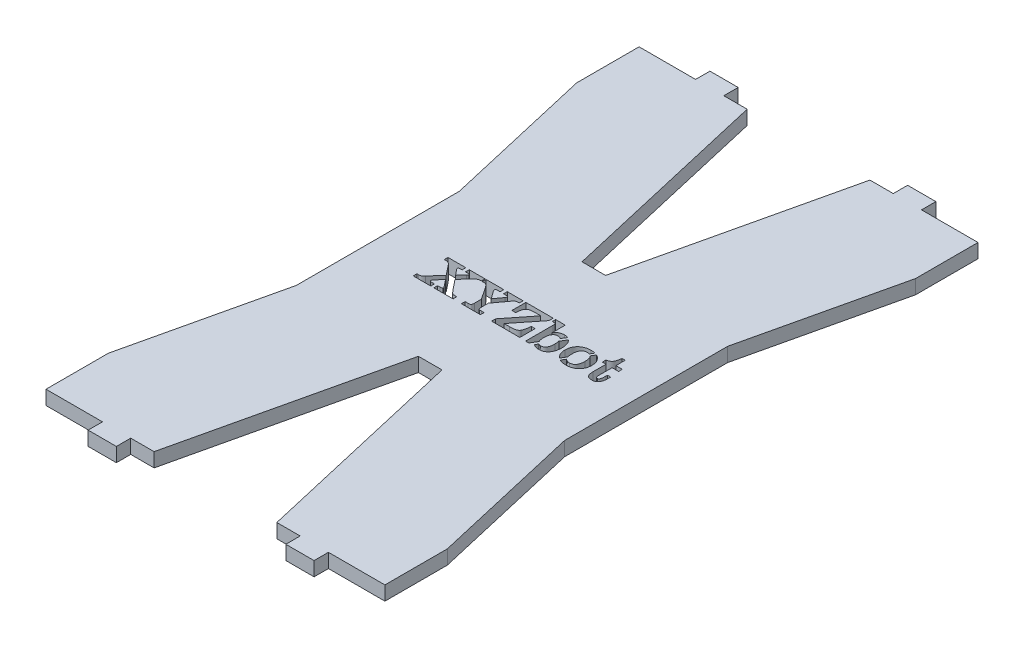
from build123d import *

# Parameters (mm, degrees)
SKETCH1_W            = 76.2
SKETCH1_H            = 133.35
BOSS_EXTRUDE1_DEPTH  = 3.175
SKETCH2_W            = 6.35
SKETCH2_H            = 3.2258
BOSS_EXTRUDE2_DEPTH  = 3.175
CUT_EXTRUDE1_DEPTH   = 4.175
BOSS_EXTRUDE4_DEPTH  = 3.175
CUT_EXTRUDE2_DEPTH   = 4.1750001
MIRROR5_COPY_1_DEPTH = 4.1750001


with BuildPart() as part:
    # Sketch1 → Boss-Extrude1 (new body)
    with BuildSketch(Plane(origin=(0, 0, 0), x_dir=(1, 0, 0), z_dir=(0, 1, 0))):
        Rectangle(SKETCH1_W, SKETCH1_H)
    extrude(amount=BOSS_EXTRUDE1_DEPTH)

    # Sketch2 → Boss-Extrude2 (add)
    with BuildSketch(Plane(origin=(0, 3.175, 0), x_dir=(1, 0, 0), z_dir=(0, 1, 0))):
        with Locations((-22.225, 68.2879)):
            Rectangle(SKETCH2_W, SKETCH2_H)
        with Locations((22.225, 68.2879)):
            Rectangle(SKETCH2_W, SKETCH2_H)
    boss_extrude2 = extrude(amount=-BOSS_EXTRUDE2_DEPTH)

    # Mirror3: Boss-Extrude2 across plane
    add(boss_extrude2.mirror(Plane.XY))

    # Sketch4 → Cut-Extrude1 (cut, through all)
    with BuildSketch(Plane(origin=(0, 3.175, 0), x_dir=(1, 0, 0), z_dir=(0, 1, 0))):
        with BuildLine():
            add(Edge.make_bspline(
                [(-15.638698165, -1.631683837), (-15.690485766, -1.691451515), (-15.78558723, -1.801207394), (-15.883175177, -1.944370795), (-15.939490037, -2.047639577), (-15.966714816, -2.113301537), (-15.987755756, -2.170565282), (-15.989626528, -2.207535866), (-15.990485478, -2.224510605)],
                knots=[0, 0, 0, 0, 0.000237095, 0.000435396, 0.000518457, 0.000589242, 0.000648993, 0.000699717, 0.000699717, 0.000699717, 0.000699717], degree=3))
            add(Edge.make_bspline(
                [(-15.990485478, -2.224510605), (-15.989620457, -2.24753442), (-15.987989932, -2.290933284), (-15.965429023, -2.350427685), (-15.930603393, -2.399456071), (-15.878870991, -2.438412475), (-15.806278072, -2.462600148), (-15.712369072, -2.481831014), (-15.592755408, -2.492103174), (-15.504617179, -2.492835488), (-15.456289929, -2.493237025)],
                knots=[0, 0, 0, 0, 6.8713e-05, 0.00012952, 0.000187834, 0.000247117, 0.000320316, 0.000415184, 0.00053462, 0.000679606, 0.000679606, 0.000679606, 0.000679606], degree=3))
            Line((-15.456289929, -2.493237025), (-14.926980315, -2.493237025))
            Line((-14.926980315, -2.493237025), (-14.926980315, -3.327103248))
            Line((-14.926980315, -3.327103248), (-18.886216229, -3.327103248))
            Line((-18.886216229, -3.327103248), (-18.886216229, -2.493237025))
            Line((-18.886216229, -2.493237025), (-18.490455502, -2.493237025))
            add(Edge.make_bspline(
                [(-18.490455502, -2.493237025), (-18.437747741, -2.491980177), (-18.337968684, -2.489600887), (-18.195873537, -2.47211743), (-18.070682723, -2.441620419), (-17.955028738, -2.397957188), (-17.843575321, -2.326543355), (-17.724242087, -2.228024589), (-17.59237661, -2.097927939), (-17.503945571, -1.998170293), (-17.456265948, -1.944383671)],
                knots=[0, 0, 0, 0, 0.000158113, 0.000299317, 0.000428484, 0.000544015, 0.000668316, 0.000823474, 0.001007748, 0.001223352, 0.001223352, 0.001223352, 0.001223352], degree=3))
            Line((-17.456265948, -1.944383671), (-15.290168142, 0.505098359))
            Line((-15.290168142, 0.505098359), (-17.070277091, 2.734713319))
            add(Edge.make_bspline(
                [(-17.070277091, 2.734713319), (-17.116065653, 2.790336686), (-17.202370607, 2.895178856), (-17.337790854, 3.031316846), (-17.467722941, 3.138633239), (-17.595840588, 3.218984537), (-17.727953317, 3.275645866), (-17.869314565, 3.317284326), (-18.024543569, 3.338860857), (-18.132096521, 3.342137704), (-18.187527538, 3.343826536)],
                knots=[0, 0, 0, 0, 0.000216046, 0.000407216, 0.000575093, 0.000720626, 0.000859205, 0.001005066, 0.001161459, 0.00132778, 0.00132778, 0.00132778, 0.00132778], degree=3))
            Line((-18.187527538, 3.343826536), (-18.573516395, 3.343826536))
            Line((-18.573516395, 3.343826536), (-18.573516395, 4.177692759))
            Line((-18.573516395, 4.177692759), (-14.568678422, 4.177692759))
            Line((-14.568678422, 4.177692759), (-14.568678422, 3.343826536))
            Line((-14.568678422, 3.343826536), (-15.086587521, 3.343826536))
            add(Edge.make_bspline(
                [(-15.086587521, 3.343826536), (-15.11163572, 3.343495713), (-15.158775097, 3.34287312), (-15.224729119, 3.330569344), (-15.282411733, 3.314457662), (-15.328519382, 3.287237596), (-15.366897499, 3.256034669), (-15.392470515, 3.215890579), (-15.410604754, 3.169952911), (-15.411725403, 3.13664339), (-15.412316515, 3.119073531)],
                knots=[0, 0, 0, 0, 7.4988e-05, 0.000141124, 0.000200876, 0.000253398, 0.000300741, 0.000347718, 0.000394611, 0.000446956, 0.000446956, 0.000446956, 0.000446956], degree=3))
            add(Edge.make_bspline(
                [(-15.412316515, 3.119073531), (-15.410329264, 3.093297243), (-15.406137786, 3.038930304), (-15.3713831, 2.955278537), (-15.309502336, 2.865205906), (-15.258685589, 2.802689179), (-15.229908278, 2.767286218)],
                knots=[0, 0, 0, 0, 7.7168e-05, 0.000162761, 0.000267565, 0.00040441, 0.00040441, 0.00040441, 0.00040441], degree=3))
            Line((-15.229908278, 2.767286218), (-14.239692139, 1.565346233))
            Line((-14.239692139, 1.565346233), (-13.032866218, 2.822660147))
            add(Edge.make_bspline(
                [(-13.032866218, 2.822660147), (-13.007017433, 2.850210094), (-12.957830972, 2.90263362), (-12.901636695, 2.987359082), (-12.861415365, 3.065389667), (-12.853760882, 3.117681889), (-12.850457982, 3.140245916)],
                knots=[0, 0, 0, 0, 0.000113071, 0.000215157, 0.000304792, 0.000372825, 0.000372825, 0.000372825, 0.000372825], degree=3))
            add(Edge.make_bspline(
                [(-12.850457982, 3.140245916), (-12.852055675, 3.156282141), (-12.855208996, 3.187932388), (-12.880309202, 3.231662924), (-12.922132284, 3.265634911), (-12.977179601, 3.295409505), (-13.048048121, 3.316977615), (-13.13376831, 3.332929053), (-13.235160774, 3.342282138), (-13.308087636, 3.343287442), (-13.347194697, 3.343826536)],
                knots=[0, 0, 0, 0, 4.7928e-05, 9.4593e-05, 0.000146531, 0.000207752, 0.000281402, 0.000367643, 0.000469091, 0.000586399, 0.000586399, 0.000586399, 0.000586399], degree=3))
            Line((-13.347194697, 3.343826536), (-13.786928838, 3.343826536))
            Line((-13.786928838, 3.343826536), (-13.786928838, 4.177692759))
            Line((-13.786928838, 4.177692759), (-10.234854165, 4.177692759))
            Line((-10.234854165, 4.177692759), (-10.234854165, 3.343826536))
            Line((-10.234854165, 3.343826536), (-10.642015407, 3.343826536))
            add(Edge.make_bspline(
                [(-10.642015407, 3.343826536), (-10.680299077, 3.34101395), (-10.761889231, 3.335019767), (-10.886186414, 3.292096874), (-11.019653992, 3.227079161), (-11.163324398, 3.136506756), (-11.315287356, 3.0179238), (-11.477991165, 2.875617342), (-11.651720779, 2.709046671), (-11.765933978, 2.58500885), (-11.826040298, 2.519732183)],
                knots=[0, 0, 0, 0, 0.000114747, 0.000244549, 0.000390964, 0.000559975, 0.000752817, 0.00096869, 0.001208273, 0.001474421, 0.001474421, 0.001474421, 0.001474421], degree=3))
            Line((-11.826040298, 2.519732183), (-11.837440813, 2.508331668))
            Line((-11.837440813, 2.508331668), (-13.506801904, 0.685877951))
            Line((-13.506801904, 0.685877951), (-11.589886778, -1.696829636))
            add(Edge.make_bspline(
                [(-11.589886778, -1.696829636), (-11.553793764, -1.741580619), (-11.484833981, -1.82708243), (-11.381555416, -1.945997428), (-11.286387937, -2.052273964), (-11.196219336, -2.142998616), (-11.114982366, -2.222686528), (-11.039077004, -2.287057271), (-10.970786068, -2.338993086), (-10.885133086, -2.388731663), (-10.768411532, -2.430971532), (-10.612923251, -2.468822484), (-10.431847279, -2.488295337), (-10.303292571, -2.491520207), (-10.234854165, -2.493237025)],
                knots=[0, 0, 0, 0, 0.00017246, 0.000329504, 0.000472472, 0.000600308, 0.000713191, 0.000813706, 0.000898724, 0.000970236, 0.001109968, 0.001269159, 0.001449556, 0.001654927, 0.001654927, 0.001654927, 0.001654927], degree=3))
            Line((-10.234854165, -2.493237025), (-9.922154332, -2.493237025))
            Line((-9.922154332, -2.493237025), (-9.922154332, -3.327103248))
            Line((-9.922154332, -3.327103248), (-14.239692139, -3.327103248))
            Line((-14.239692139, -3.327103248), (-14.239692139, -2.493237025))
            Line((-14.239692139, -2.493237025), (-13.721783039, -2.493237025))
            add(Edge.make_bspline(
                [(-13.721783039, -2.493237025), (-13.678892894, -2.492517178), (-13.599538096, -2.491185328), (-13.48943544, -2.484121276), (-13.398086192, -2.469200598), (-13.32303738, -2.45168885), (-13.265098193, -2.423318795), (-13.222260179, -2.387916962), (-13.196700104, -2.341137923), (-13.193925025, -2.307337082), (-13.192473425, -2.289656404)],
                knots=[0, 0, 0, 0, 0.000128704, 0.000238127, 0.000330501, 0.000406351, 0.000468261, 0.000522498, 0.000570591, 0.00062334, 0.00062334, 0.00062334, 0.00062334], degree=3))
            add(Edge.make_bspline(
                [(-13.192473425, -2.289656404), (-13.194174591, -2.261801444), (-13.197736273, -2.203482329), (-13.224131195, -2.115776548), (-13.26309585, -2.025701673), (-13.303651651, -1.971900138), (-13.324393667, -1.944383671)],
                knots=[0, 0, 0, 0, 8.3459e-05, 0.000174736, 0.000273131, 0.000376135, 0.000376135, 0.000376135, 0.000376135], degree=3))
            Line((-13.324393667, -1.944383671), (-14.558906552, -0.390656372))
            Line((-14.558906552, -0.390656372), (-15.638698165, -1.631683837))
        make_face()
        with BuildLine():
            add(Edge.make_bspline(
                [(-5.127423549, -1.796176979), (-5.125840843, -1.86514528), (-5.122990046, -1.989372053), (-5.104314954, -2.15639366), (-5.069354339, -2.282370853), (-5.023912537, -2.363797322), (-4.971161517, -2.403080683), (-4.923115364, -2.427054709), (-4.864193973, -2.448453956), (-4.793275858, -2.463068058), (-4.712197141, -2.479425369), (-4.618752394, -2.485068094), (-4.514643876, -2.493170108), (-4.441245033, -2.493213975), (-4.402676539, -2.493237025)],
                knots=[0, 0, 0, 0, 0.000206998, 0.000372848, 0.000502169, 0.000598851, 0.000644132, 0.000697307, 0.000759644, 0.000831544, 0.000914285, 0.001007474, 0.001111911, 0.001227556, 0.001227556, 0.001227556, 0.001227556], degree=3))
            Line((-4.402676539, -2.493237025), (-3.772390937, -2.493237025))
            Line((-3.772390937, -2.493237025), (-3.772390937, -3.327103248))
            Line((-3.772390937, -3.327103248), (-8.04595533, -3.327103248))
            Line((-8.04595533, -3.327103248), (-8.04595533, -2.493237025))
            Line((-8.04595533, -2.493237025), (-7.410783793, -2.493237025))
            add(Edge.make_bspline(
                [(-7.410783793, -2.493237025), (-7.372219211, -2.493191042), (-7.298827813, -2.493103533), (-7.19466939, -2.485294067), (-7.101475721, -2.478718268), (-7.020507916, -2.46540101), (-6.950392646, -2.449783487), (-6.892787526, -2.428719804), (-6.84484373, -2.406110137), (-6.792918514, -2.366917988), (-6.746923129, -2.285954663), (-6.715060941, -2.15861047), (-6.692460689, -1.99126836), (-6.691471219, -1.865754228), (-6.690922718, -1.796176979)],
                knots=[0, 0, 0, 0, 0.000115645, 0.000220082, 0.000313271, 0.000395739, 0.000466054, 0.000528391, 0.000579376, 0.000624657, 0.000721339, 0.000850197, 0.001017877, 0.001226445, 0.001226445, 0.001226445, 0.001226445], degree=3))
            Line((-6.690922718, -1.796176979), (-6.690922718, -0.193590331))
            Line((-6.690922718, -0.193590331), (-8.529662885, 2.563705597))
            add(Edge.make_bspline(
                [(-8.529662885, 2.563705597), (-8.578130173, 2.632264546), (-8.669101195, 2.760946752), (-8.810745181, 2.931305021), (-8.945353419, 3.067760726), (-9.075794777, 3.173600039), (-9.207864949, 3.250371117), (-9.345175809, 3.30592008), (-9.491930187, 3.336643223), (-9.592491862, 3.341404218), (-9.643656042, 3.343826536)],
                knots=[0, 0, 0, 0, 0.000251814, 0.000472644, 0.000663814, 0.000826091, 0.000974976, 0.001120446, 0.001268662, 0.001422179, 0.001422179, 0.001422179, 0.001422179], degree=3))
            Line((-9.643656042, 3.343826536), (-10.026387609, 3.343826536))
            Line((-10.026387609, 3.343826536), (-10.026387609, 4.177692759))
            Line((-10.026387609, 4.177692759), (-6.036207441, 4.177692759))
            Line((-6.036207441, 4.177692759), (-6.036207441, 3.343826536))
            Line((-6.036207441, 3.343826536), (-6.57691757, 3.343826536))
            add(Edge.make_bspline(
                [(-6.57691757, 3.343826536), (-6.616049839, 3.343477281), (-6.689080356, 3.342825483), (-6.789806409, 3.331238358), (-6.874625283, 3.314694557), (-6.942165524, 3.288634697), (-6.996061598, 3.25669823), (-7.030858496, 3.213096546), (-7.056985144, 3.164127765), (-7.058306277, 3.127045841), (-7.05899648, 3.107673016)],
                knots=[0, 0, 0, 0, 0.000117308, 0.000218925, 0.000303896, 0.000375575, 0.000435659, 0.000488833, 0.00054128, 0.000598653, 0.000598653, 0.000598653, 0.000598653], degree=3))
            add(Edge.make_bspline(
                [(-7.05899648, 3.107673016), (-7.056728487, 3.080891253), (-7.051859568, 3.023396266), (-7.02180706, 2.934280461), (-6.972454458, 2.837207219), (-6.931427928, 2.770770992), (-6.909161143, 2.734713319)],
                knots=[0, 0, 0, 0, 8.04e-05, 0.000172602, 0.000279672, 0.000406758, 0.000406758, 0.000406758, 0.000406758], degree=3))
            Line((-6.909161143, 2.734713319), (-5.658361809, 0.966004885))
            Line((-5.658361809, 0.966004885), (-4.348931255, 2.799859117))
            add(Edge.make_bspline(
                [(-4.348931255, 2.799859117), (-4.325333882, 2.834671099), (-4.284281313, 2.895233826), (-4.238304619, 2.983428087), (-4.210268674, 3.062447113), (-4.207151069, 3.114515973), (-4.205610498, 3.140245916)],
                knots=[0, 0, 0, 0, 0.000126039, 0.000219271, 0.000298071, 0.000375049, 0.000375049, 0.000375049, 0.000375049], degree=3))
            add(Edge.make_bspline(
                [(-4.205610498, 3.140245916), (-4.206906408, 3.156140689), (-4.209411394, 3.186865197), (-4.228045341, 3.230771861), (-4.263197821, 3.264825139), (-4.307704114, 3.294559638), (-4.364837121, 3.317192084), (-4.432939414, 3.332473232), (-4.512058524, 3.342322626), (-4.568222563, 3.343304153), (-4.598113935, 3.343826536)],
                knots=[0, 0, 0, 0, 4.7678e-05, 9.2161e-05, 0.000139392, 0.000192241, 0.000252126, 0.000322441, 0.000401224, 0.000490859, 0.000490859, 0.000490859, 0.000490859], degree=3))
            Line((-4.598113935, 3.343826536), (-5.241428697, 3.343826536))
            Line((-5.241428697, 3.343826536), (-5.241428697, 4.177692759))
            Line((-5.241428697, 4.177692759), (-1.68772538, 4.177692759))
            Line((-1.68772538, 4.177692759), (-1.68772538, 3.343826536))
            Line((-1.68772538, 3.343826536), (-1.959709089, 3.343826536))
            add(Edge.make_bspline(
                [(-1.959709089, 3.343826536), (-2.009194964, 3.342730369), (-2.104241605, 3.340624978), (-2.238943886, 3.320579484), (-2.360219459, 3.291145884), (-2.468150222, 3.243445753), (-2.571109996, 3.178051903), (-2.672237808, 3.089088531), (-2.777765069, 2.976528894), (-2.844297305, 2.890082975), (-2.879893495, 2.843832532)],
                knots=[0, 0, 0, 0, 0.00014835, 0.000284933, 0.000407785, 0.000521557, 0.000637225, 0.000772364, 0.000924448, 0.001099442, 0.001099442, 0.001099442, 0.001099442], degree=3))
            Line((-2.879893495, 2.843832532), (-5.127423549, -0.191961686))
            Line((-5.127423549, -0.191961686), (-5.127423549, -1.796176979))
        make_face()
        with BuildLine():
            Line((-1.270792268, -3.327103248), (-1.270792268, -2.432977161))
            Line((-1.270792268, -2.432977161), (3.21775326, 3.239593259))
            Line((3.21775326, 3.239593259), (1.936009672, 3.239593259))
            add(Edge.make_bspline(
                [(1.936009672, 3.239593259), (1.867600188, 3.239455864), (1.735632501, 3.239190819), (1.545584488, 3.23228615), (1.370748062, 3.222544457), (1.211446179, 3.210505765), (1.067604308, 3.192022404), (0.93853921, 3.17180414), (0.824890882, 3.145904404), (0.695418437, 3.107482131), (0.550750043, 3.046643999), (0.398296176, 2.947257708), (0.262751773, 2.827288009), (0.190717386, 2.731207806), (0.154272078, 2.68259668)],
                knots=[0, 0, 0, 0, 0.000205216, 0.000395879, 0.000570417, 0.000730555, 0.000874992, 0.001005385, 0.00112233, 0.001224352, 0.001410402, 0.001590653, 0.001768243, 0.001950105, 0.001950105, 0.001950105, 0.001950105], degree=3))
            add(Edge.make_bspline(
                [(0.154272078, 2.68259668), (0.126781408, 2.635840821), (0.070329744, 2.539828391), (0.000452489, 2.382109143), (-0.057163169, 2.208897125), (-0.107042703, 2.019816364), (-0.143576277, 1.810564937), (-0.1713604, 1.579005765), (-0.186421956, 1.322861104), (-0.190499306, 1.144085961), (-0.1926293, 1.050694423)],
                knots=[0, 0, 0, 0, 0.00016262, 0.000333938, 0.000516259, 0.000709821, 0.000920023, 0.001152942, 0.001409158, 0.001689403, 0.001689403, 0.001689403, 0.001689403], degree=3))
            Line((-0.1926293, 1.050694423), (-1.062325712, 1.050694423))
            Line((-1.062325712, 1.050694423), (-1.062325712, 4.177692759))
            Line((-1.062325712, 4.177692759), (5.087437682, 4.177692759))
            Line((5.087437682, 4.177692759), (5.087437682, 3.228192744))
            Line((5.087437682, 3.228192744), (0.615178603, -2.389003747))
            Line((0.615178603, -2.389003747), (1.820375879, -2.389003747))
            add(Edge.make_bspline(
                [(1.820375879, -2.389003747), (1.892040398, -2.388824042), (2.030516605, -2.388476802), (2.231474239, -2.382067218), (2.41876575, -2.370260784), (2.592675397, -2.356412699), (2.752998209, -2.337017816), (2.899039745, -2.312473831), (3.031939797, -2.285399067), (3.18695254, -2.243118416), (3.359641972, -2.177459566), (3.537858711, -2.071752456), (3.689330258, -1.946462643), (3.760666058, -1.841525364), (3.795922224, -1.789662399)],
                knots=[0, 0, 0, 0, 0.000214987, 0.000415417, 0.000603057, 0.000777938, 0.000938737, 0.001087337, 0.001222131, 0.001345404, 0.001569211, 0.001773669, 0.001965338, 0.002152632, 0.002152632, 0.002152632, 0.002152632], degree=3))
            add(Edge.make_bspline(
                [(3.795922224, -1.789662399), (3.824456661, -1.735788944), (3.883533647, -1.624250688), (3.958462054, -1.442491728), (4.020743049, -1.240877462), (4.076643199, -1.019677021), (4.122725973, -0.774677619), (4.165894419, -0.503882914), (4.198972795, -0.204876636), (4.215605107, 0.003970196), (4.22425585, 0.112594922)],
                knots=[0, 0, 0, 0, 0.000182822, 0.000378511, 0.000588663, 0.000815395, 0.001062617, 0.001336268, 0.001637884, 0.001964788, 0.001964788, 0.001964788, 0.001964788], degree=3))
            Line((4.22425585, 0.112594922), (5.087437682, 0.112594922))
            Line((5.087437682, 0.112594922), (5.087437682, -3.327103248))
            Line((5.087437682, -3.327103248), (-1.270792268, -3.327103248))
        make_face()
        with BuildLine():
            Line((7.62812383, -2.652844231), (7.180246465, -3.387363111))
            Line((7.180246465, -3.387363111), (6.442470295, -3.387363111))
            Line((6.442470295, -3.387363111), (6.442470295, 2.788458603))
            add(Edge.make_bspline(
                [(6.442470295, 2.788458603), (6.44076308, 2.852528255), (6.437669848, 2.968613445), (6.420099839, 3.12522753), (6.382120287, 3.243925883), (6.327664323, 3.333477802), (6.242250659, 3.388386414), (6.13305901, 3.424765703), (5.993013059, 3.443403873), (5.889855322, 3.446412194), (5.833357077, 3.448059814)],
                knots=[0, 0, 0, 0, 0.000192353, 0.000348516, 0.000470577, 0.000564532, 0.000655794, 0.000768088, 0.000908132, 0.001077707, 0.001077707, 0.001077707, 0.001077707], degree=3))
            Line((5.833357077, 3.448059814), (5.608604072, 3.448059814))
            Line((5.608604072, 3.448059814), (5.608604072, 4.177692759))
            Line((5.608604072, 4.177692759), (7.797502907, 4.177692759))
            Line((7.797502907, 4.177692759), (7.797502907, 1.20378705))
            add(Edge.make_bspline(
                [(7.797502907, 1.20378705), (7.84977781, 1.28506415), (7.951646696, 1.443450051), (8.133620225, 1.649910619), (8.329136843, 1.825052801), (8.544108028, 1.963763585), (8.779885032, 2.069354101), (9.037590151, 2.143239611), (9.318581437, 2.190172423), (9.513897407, 2.194841768), (9.61507069, 2.19726048)],
                knots=[0, 0, 0, 0, 0.000289555, 0.000564261, 0.000822729, 0.001074806, 0.001328477, 0.001594924, 0.001877131, 0.002180413, 0.002180413, 0.002180413, 0.002180413], degree=3))
            add(Edge.make_bspline(
                [(9.61507069, 2.19726048), (9.699344427, 2.195274315), (9.864350119, 2.191385459), (10.104808657, 2.154993094), (10.331286322, 2.094299485), (10.544926058, 2.01124584), (10.745071827, 1.902810969), (10.931344888, 1.77022201), (11.103832623, 1.613705228), (11.261575187, 1.434438555), (11.402351335, 1.233963492), (11.527234688, 1.01637224), (11.631533676, 0.7804591), (11.715654233, 0.526589995), (11.782692946, 0.255501442), (11.829108379, -0.033202244), (11.8569559, -0.339075644), (11.860685877, -0.548574557), (11.862600744, -0.656125502)],
                knots=[0, 0, 0, 0, 0.000252697, 0.000494774, 0.000727466, 0.000954899, 0.001180806, 0.001408566, 0.001639179, 0.001878035, 0.002123404, 0.002372885, 0.00262953, 0.002895797, 0.003174276, 0.00346639, 0.003772202, 0.004094822, 0.004094822, 0.004094822, 0.004094822], degree=3))
            add(Edge.make_bspline(
                [(11.862600744, -0.656125502), (11.860873959, -0.763695977), (11.857500858, -0.97382408), (11.826923118, -1.280012381), (11.781662646, -1.569638947), (11.712038775, -1.840985219), (11.626392843, -2.096438719), (11.520648883, -2.335085331), (11.394373264, -2.556455723), (11.250080041, -2.759699868), (11.089174818, -2.942232211), (10.914078163, -3.101570646), (10.725545777, -3.236220169), (10.523370853, -3.346489397), (10.306680624, -3.431772929), (10.076243381, -3.490584122), (9.833056943, -3.530448542), (9.666268425, -3.533835572), (9.580869146, -3.535569803)],
                knots=[0, 0, 0, 0, 0.00032262, 0.000630205, 0.000922319, 0.001201193, 0.001469524, 0.001729807, 0.001982924, 0.002232835, 0.002476289, 0.002711502, 0.002941534, 0.003169649, 0.00340071, 0.003638123, 0.003882056, 0.004138007, 0.004138007, 0.004138007, 0.004138007], degree=3))
            add(Edge.make_bspline(
                [(9.580869146, -3.535569803), (9.483538185, -3.533312714), (9.292331522, -3.528878661), (9.013521428, -3.486802032), (8.748799904, -3.420814065), (8.499260713, -3.325127412), (8.261685436, -3.202446536), (8.038673847, -3.046645591), (7.822376747, -2.866277419), (7.693844456, -2.725054023), (7.62812383, -2.652844231)],
                knots=[0, 0, 0, 0, 0.000291818, 0.000573277, 0.000843858, 0.001108822, 0.00137325, 0.001643845, 0.001923489, 0.002216083, 0.002216083, 0.002216083, 0.002216083], degree=3))
        make_face()
        with BuildLine():
            add(Edge.make_bspline(
                [(10.299101576, -0.664268727), (10.298213573, -0.585529441), (10.296497151, -0.433334156), (10.281980377, -0.213136152), (10.25715932, -0.008876103), (10.225839364, 0.180827104), (10.182393091, 0.354668477), (10.127826359, 0.512167201), (10.06692996, 0.655566268), (9.99339709, 0.782385022), (9.911031827, 0.895467108), (9.818511201, 0.993595976), (9.714504089, 1.075838955), (9.601131318, 1.143227925), (9.477371982, 1.195792829), (9.343339501, 1.23331666), (9.198770603, 1.2539168), (9.099395161, 1.257380269), (9.048302241, 1.259160979)],
                knots=[0, 0, 0, 0, 0.000236204, 0.000456559, 0.0006616, 0.000853311, 0.001033038, 0.001198368, 0.001352986, 0.001499645, 0.001637109, 0.001771894, 0.001902886, 0.002033604, 0.002166406, 0.002305109, 0.002449985, 0.002603294, 0.002603294, 0.002603294, 0.002603294], degree=3))
            add(Edge.make_bspline(
                [(9.048302241, 1.259160979), (9.000948658, 1.257695432), (8.907762477, 1.254811412), (8.772337199, 1.229141516), (8.6441389, 1.191195766), (8.524873653, 1.133698237), (8.412266268, 1.062838526), (8.308713201, 0.973314755), (8.214527985, 0.86776279), (8.126076219, 0.749088215), (8.048565975, 0.615559688), (7.981576617, 0.469190747), (7.924814006, 0.310551887), (7.877562742, 0.139705155), (7.842246141, -0.043921307), (7.816597936, -0.239701556), (7.799687525, -0.447906055), (7.798243254, -0.590945395), (7.797502907, -0.664268727)],
                knots=[0, 0, 0, 0, 0.000141926, 0.000279293, 0.000412205, 0.000541884, 0.000675165, 0.000810303, 0.000950971, 0.001098856, 0.001253603, 0.001413193, 0.001581141, 0.001758551, 0.001944445, 0.002141612, 0.002350714, 0.002570635, 0.002570635, 0.002570635, 0.002570635], degree=3))
            add(Edge.make_bspline(
                [(7.797502907, -0.664268727), (7.79822546, -0.73759602), (7.799635018, -0.88064309), (7.816791282, -1.088792848), (7.841662594, -1.285398161), (7.880099844, -1.468842714), (7.924159967, -1.641769295), (7.983333296, -1.801020618), (8.052006318, -1.948592245), (8.129293769, -2.084096007), (8.217383614, -2.204170605), (8.312017072, -2.310596979), (8.416798915, -2.39857703), (8.528729856, -2.470591888), (8.646576341, -2.529473378), (8.773964497, -2.567400909), (8.908279203, -2.593240044), (9.000942602, -2.596039513), (9.048302241, -2.597470302)],
                knots=[0, 0, 0, 0, 0.000219921, 0.000429023, 0.00062619, 0.000814, 0.000990984, 0.00116102, 0.001322773, 0.001478928, 0.001628124, 0.001768792, 0.001905171, 0.002037082, 0.002167465, 0.002298821, 0.002434586, 0.002576512, 0.002576512, 0.002576512, 0.002576512], degree=3))
            add(Edge.make_bspline(
                [(9.048302241, -2.597470302), (9.099401635, -2.595703851), (9.198789667, -2.592268113), (9.34326937, -2.571471523), (9.477827399, -2.534587745), (9.600648376, -2.479423766), (9.715152129, -2.4128395), (9.817883344, -2.328424777), (9.911692269, -2.230509757), (9.992807112, -2.115911082), (10.067391773, -1.988690115), (10.128098921, -1.843459885), (10.181802679, -1.684100058), (10.225939914, -1.509395413), (10.257129585, -1.319652226), (10.281989191, -1.115404006), (10.296494691, -0.895202543), (10.298212734, -0.743007756), (10.299101576, -0.664268727)],
                knots=[0, 0, 0, 0, 0.000153309, 0.000298185, 0.000436888, 0.000570338, 0.000701056, 0.000833067, 0.000967851, 0.00110663, 0.00125329, 0.001409402, 0.001577815, 0.001757543, 0.001949253, 0.002154294, 0.002374649, 0.002610853, 0.002610853, 0.002610853, 0.002610853], degree=3))
        make_face(mode=Mode.SUBTRACT)
        with BuildLine():
            add(Edge.make_bspline(
                [(12.592233689, -0.677297887), (12.594556948, -0.571296569), (12.599100927, -0.363972414), (12.639846383, -0.061618223), (12.701651607, 0.225453699), (12.794111851, 0.495128113), (12.910035817, 0.749859143), (13.051983453, 0.988031582), (13.220013025, 1.210460857), (13.413095816, 1.41440026), (13.627840632, 1.598055438), (13.860569793, 1.759133641), (14.110968039, 1.894344276), (14.37825257, 2.005848867), (14.662675124, 2.091677005), (14.963461872, 2.153760391), (15.281357191, 2.189345463), (15.498733758, 2.194578953), (15.610112813, 2.19726048)],
                knots=[0, 0, 0, 0, 0.000317853, 0.000621677, 0.000913682, 0.001197464, 0.001475127, 0.001751925, 0.002027493, 0.002309757, 0.002592752, 0.002873749, 0.003157236, 0.00344488, 0.003741119, 0.004047114, 0.004365096, 0.004699222, 0.004699222, 0.004699222, 0.004699222], degree=3))
            add(Edge.make_bspline(
                [(15.610112813, 2.19726048), (15.722034047, 2.194572092), (15.94049196, 2.189324656), (16.259482139, 2.153884528), (16.56085888, 2.091774437), (16.845524466, 2.00531741), (17.114348268, 1.895239194), (17.364174762, 1.756547954), (17.599374933, 1.59723898), (17.813104977, 1.411003811), (18.006775273, 1.206856342), (18.17628647, 0.984816484), (18.320176889, 0.747046262), (18.435820076, 0.49182419), (18.528094341, 0.222690368), (18.59036206, -0.063744466), (18.630785435, -0.365069774), (18.635406871, -0.571843302), (18.637763806, -0.677297887)],
                knots=[0, 0, 0, 0, 0.000335754, 0.000655354, 0.000961349, 0.001257588, 0.001546735, 0.001831003, 0.002113341, 0.002397399, 0.002679662, 0.002956215, 0.003233851, 0.003511514, 0.003795296, 0.004085711, 0.004389535, 0.004705761, 0.004705761, 0.004705761, 0.004705761], degree=3))
            add(Edge.make_bspline(
                [(18.637763806, -0.677297887), (18.635420754, -0.78221339), (18.630826922, -0.987912689), (18.590146535, -1.288099141), (18.528377145, -1.573579386), (18.435767188, -1.841542647), (18.320242713, -2.095228279), (18.175735368, -2.33145335), (18.007308438, -2.553243879), (17.812987616, -2.755817196), (17.599324173, -2.94046146), (17.36416605, -3.098281458), (17.113873802, -3.234768141), (16.84588432, -3.345832727), (16.560520391, -3.429524347), (16.259534492, -3.492361417), (15.940477848, -3.527588812), (15.722029267, -3.532866114), (15.610112813, -3.535569803)],
                knots=[0, 0, 0, 0, 0.000314598, 0.000616808, 0.000907223, 0.001189463, 0.001465647, 0.001741888, 0.002018441, 0.002299523, 0.002582519, 0.00286394, 0.003147427, 0.003436574, 0.003732343, 0.004038337, 0.004357938, 0.004693692, 0.004693692, 0.004693692, 0.004693692], degree=3))
            add(Edge.make_bspline(
                [(15.610112813, -3.535569803), (15.498737962, -3.532874042), (15.281369602, -3.527612772), (14.963415748, -3.492225864), (14.662992533, -3.429464097), (14.377969471, -3.346226449), (14.110928704, -3.234258554), (13.86112669, -3.098833851), (13.627242036, -2.939904298), (13.413777243, -2.755830162), (13.219399358, -2.553688427), (13.05255184, -2.331390622), (12.909968647, -2.094787377), (12.79413962, -1.841593477), (12.70164562, -1.573565222), (12.63984384, -1.288103132), (12.599172469, -0.987911626), (12.594577382, -0.782213031), (12.592233689, -0.677297887)],
                knots=[0, 0, 0, 0, 0.000334126, 0.000652109, 0.000958103, 0.001253872, 0.001541515, 0.001825003, 0.002105077, 0.002388073, 0.002669155, 0.002944723, 0.003220123, 0.003496307, 0.003778547, 0.004068962, 0.004371171, 0.00468577, 0.00468577, 0.00468577, 0.00468577], degree=3))
        make_face()
        with BuildLine():
            add(Edge.make_bspline(
                [(14.155732857, -0.677297887), (14.156302436, -0.759314979), (14.157409145, -0.918676535), (14.176408664, -1.149085258), (14.203199524, -1.364039592), (14.241920717, -1.562794504), (14.292051608, -1.745934857), (14.353708425, -1.91295811), (14.426971377, -2.063794664), (14.511733585, -2.198613957), (14.60897041, -2.316872568), (14.716676266, -2.421255945), (14.838549047, -2.506876512), (14.969956402, -2.580368099), (15.113916697, -2.634911113), (15.269015204, -2.674472526), (15.435736735, -2.696879601), (15.550872975, -2.700064756), (15.610112813, -2.70170358)],
                knots=[0, 0, 0, 0, 0.000245974, 0.000477934, 0.000693076, 0.000895579, 0.001084845, 0.001262121, 0.00142892, 0.001587058, 0.001738662, 0.001887262, 0.002035504, 0.002184202, 0.002337848, 0.002495852, 0.002663531, 0.00284124, 0.00284124, 0.00284124, 0.00284124], degree=3))
            add(Edge.make_bspline(
                [(15.610112813, -2.70170358), (15.669341382, -2.700015653), (15.78445572, -2.696735062), (15.951467617, -2.674982173), (16.106151482, -2.632997975), (16.250110908, -2.578057899), (16.383489493, -2.507660735), (16.505088696, -2.421089368), (16.613428272, -2.316349991), (16.711659697, -2.196956661), (16.798030818, -2.061333076), (16.871090133, -1.909354482), (16.934724212, -1.742797072), (16.986775134, -1.560299349), (17.0245727, -1.361725926), (17.054741277, -1.148230789), (17.069844246, -0.918008765), (17.072758948, -0.759289689), (17.074264638, -0.677297887)],
                knots=[0, 0, 0, 0, 0.000177709, 0.000345388, 0.000503803, 0.000657449, 0.000806805, 0.000955048, 0.001103648, 0.001257544, 0.00141793, 0.001584729, 0.00176258, 0.001952288, 0.002153193, 0.00236855, 0.002598765, 0.002844777, 0.002844777, 0.002844777, 0.002844777], degree=3))
            add(Edge.make_bspline(
                [(17.074264638, -0.677297887), (17.072768299, -0.594761855), (17.069871088, -0.434955583), (17.054597779, -0.202592165), (17.024750218, 0.013124132), (16.986680767, 0.213798769), (16.935103624, 0.397554794), (16.870628983, 0.564856549), (16.798487362, 0.717806971), (16.711678133, 0.853806393), (16.612947476, 0.973203134), (16.505219757, 1.079527307), (16.383522582, 1.167605175), (16.250505206, 1.239864772), (16.106385586, 1.295209409), (15.951043438, 1.333988401), (15.784652525, 1.359156989), (15.66938227, 1.361955383), (15.610112813, 1.363394257)],
                knots=[0, 0, 0, 0, 0.00024764, 0.00047948, 0.000698065, 0.000900567, 0.001091841, 0.001269692, 0.001437956, 0.001598342, 0.001752238, 0.001901967, 0.002051164, 0.002201291, 0.002354937, 0.002512941, 0.002680849, 0.002858558, 0.002858558, 0.002858558, 0.002858558], degree=3))
            add(Edge.make_bspline(
                [(15.610112813, 1.363394257), (15.551377168, 1.361987391), (15.437169767, 1.359251839), (15.271467055, 1.333497967), (15.116351154, 1.29583702), (14.972990512, 1.239749508), (14.841380445, 1.167754187), (14.721409804, 1.078404759), (14.612112866, 0.974310186), (14.51497222, 0.853669455), (14.430478249, 0.716916745), (14.35535786, 0.565691971), (14.293322804, 0.397379966), (14.244337347, 0.213348678), (14.202220167, 0.013528568), (14.176872145, -0.202870692), (14.157263184, -0.434814795), (14.156253939, -0.594731532), (14.155732857, -0.677297887)],
                knots=[0, 0, 0, 0, 0.000176082, 0.000342379, 0.000501962, 0.00065409, 0.000802788, 0.000950672, 0.001101574, 0.001254442, 0.001413957, 0.001582937, 0.001760212, 0.001951049, 0.002153872, 0.002372245, 0.002604205, 0.002851807, 0.002851807, 0.002851807, 0.002851807], degree=3))
        make_face(mode=Mode.SUBTRACT)
        with BuildLine():
            Line((19.992796418, -1.726145245), (19.992796418, 1.154927701))
            Line((19.992796418, 1.154927701), (19.158930195, 1.154927701))
            Line((19.158930195, 1.154927701), (19.158930195, 1.936677285))
            add(Edge.make_bspline(
                [(19.158930195, 1.936677285), (19.217808178, 1.948144023), (19.332865766, 1.970551977), (19.497449294, 2.020541468), (19.652049565, 2.078126167), (19.793726396, 2.150133634), (19.923612596, 2.233055123), (20.039412313, 2.329284684), (20.147082737, 2.432910514), (20.240498738, 2.552550734), (20.323974677, 2.685962332), (20.398948656, 2.834662657), (20.464242501, 3.000391416), (20.5182911, 3.182770631), (20.566074859, 3.38166451), (20.604391099, 3.597015893), (20.634146882, 3.829641868), (20.645101072, 3.990320958), (20.650768985, 4.073459482)],
                knots=[0, 0, 0, 0, 0.000179838, 0.000351434, 0.00051537, 0.000674153, 0.000827297, 0.000976609, 0.001125174, 0.001274734, 0.001430625, 0.001596691, 0.001773615, 0.001964243, 0.00216689, 0.002386998, 0.002620116, 0.002870064, 0.002870064, 0.002870064, 0.002870064], degree=3))
            Line((20.650768985, 4.073459482), (21.37063006, 4.073459482))
            Line((21.37063006, 4.073459482), (21.37063006, 1.988793924))
            Line((21.37063006, 1.988793924), (22.807094921, 1.988793924))
            Line((22.807094921, 1.988793924), (22.807094921, 1.154927701))
            Line((22.807094921, 1.154927701), (21.347829031, 1.154927701))
            Line((21.347829031, 1.154927701), (21.347829031, -1.895524322))
            add(Edge.make_bspline(
                [(21.347829031, -1.895524322), (21.348180999, -1.959102928), (21.348823555, -2.075172685), (21.367117859, -2.232709655), (21.391973348, -2.357121284), (21.430416589, -2.453308067), (21.491176991, -2.519771923), (21.566869704, -2.566975493), (21.661772082, -2.591978259), (21.72988488, -2.595553895), (21.766390787, -2.597470302)],
                knots=[0, 0, 0, 0, 0.000190614, 0.000347987, 0.000474823, 0.000571065, 0.00065411, 0.000740428, 0.000835281, 0.000944837, 0.000944837, 0.000944837, 0.000944837], degree=3))
            add(Edge.make_bspline(
                [(21.766390787, -2.597470302), (21.812116728, -2.594540065), (21.899614313, -2.588932993), (22.019066976, -2.530801025), (22.11385254, -2.436652287), (22.168244509, -2.32942504), (22.200210307, -2.224218752), (22.225200998, -2.124973701), (22.243616819, -2.006098326), (22.260090669, -1.869251496), (22.270097287, -1.71317344), (22.280935525, -1.539528615), (22.284911434, -1.346687586), (22.285578768, -1.212035565), (22.285928532, -1.141461702)],
                knots=[0, 0, 0, 0, 0.00013636, 0.000260927, 0.000388763, 0.000530838, 0.000616338, 0.000718645, 0.000837525, 0.000976914, 0.001132055, 0.001306594, 0.001498836, 0.001710566, 0.001710566, 0.001710566, 0.001710566], degree=3))
            Line((22.285928532, -1.141461702), (22.285928532, -0.825504579))
            Line((22.285928532, -0.825504579), (23.000903672, -0.825504579))
            add(Edge.make_bspline(
                [(23.000903672, -0.825504579), (23.003215381, -0.856440081), (23.008038348, -0.920981448), (23.012964255, -1.027412552), (23.016538081, -1.158268071), (23.015915941, -1.255463632), (23.015561477, -1.310840779)],
                knots=[0, 0, 0, 0, 9.3061e-05, 0.000194155, 0.000319603, 0.000485725, 0.000485725, 0.000485725, 0.000485725], degree=3))
            add(Edge.make_bspline(
                [(23.015561477, -1.310840779), (23.014304518, -1.405335532), (23.011882108, -1.587445774), (22.993625755, -1.85050294), (22.965511054, -2.093818456), (22.923175644, -2.316856505), (22.870230329, -2.520419966), (22.803744816, -2.703145439), (22.725517489, -2.866042258), (22.635297484, -3.009562703), (22.532234787, -3.136122853), (22.411062965, -3.241539339), (22.279007165, -3.334697845), (22.129495773, -3.407571143), (21.966544612, -3.466885698), (21.787995525, -3.506243324), (21.595564662, -3.531455877), (21.462463866, -3.534164813), (21.39343109, -3.535569803)],
                knots=[0, 0, 0, 0, 0.000283459, 0.000546282, 0.000790715, 0.001017822, 0.001226803, 0.001421049, 0.001600237, 0.001767869, 0.001928643, 0.002087835, 0.002248213, 0.002412092, 0.002585189, 0.00276732, 0.002959431, 0.00316643, 0.00316643, 0.00316643, 0.00316643], degree=3))
            add(Edge.make_bspline(
                [(21.39343109, -3.535569803), (21.334165563, -3.534639541), (21.219568491, -3.532840767), (21.054772173, -3.510028132), (20.901059602, -3.479555246), (20.76150882, -3.4293129), (20.632314664, -3.370071198), (20.51758488, -3.293622296), (20.414030265, -3.20568775), (20.323328408, -3.102964696), (20.244184335, -2.985194417), (20.176322532, -2.851611799), (20.119966316, -2.702210844), (20.071936061, -2.537991161), (20.037548333, -2.357338882), (20.011665902, -2.161051606), (19.994898445, -1.949015533), (19.993513564, -1.802181621), (19.992796418, -1.726145245)],
                knots=[0, 0, 0, 0, 0.000177642, 0.000343492, 0.000498419, 0.00064676, 0.000787362, 0.00092378, 0.001058918, 0.001193899, 0.001333479, 0.001483526, 0.001642317, 0.001811892, 0.001996188, 0.002193355, 0.002405704, 0.002633767, 0.002633767, 0.002633767, 0.002633767], degree=3))
        make_face()
    extrude(amount=-CUT_EXTRUDE1_DEPTH, mode=Mode.SUBTRACT)

    # Sketch5 → Boss-Extrude4 (add)
    with BuildSketch(Plane(origin=(0, 3.175, 0), x_dir=(1, 0, 0), z_dir=(0, 1, 0))):
        Polygon((7.62812383, -2.652844231), (10.575632779, 2.181070445), (11.117793351, 1.85048473), (7.722407036, -3.717948826), (7.180246465, -3.387363111), align=None)
        Polygon((17.060154022, 2.836040592), (13.081663188, -3.688684375), (13.717927129, -3.688684375), (17.695154022, 2.83396773), align=None)
    extrude(amount=-BOSS_EXTRUDE4_DEPTH)

    # Sketch6 → Cut-Extrude2 (cut, through all)
    with BuildSketch(Plane(origin=(0, 3.175, 0), x_dir=(1, 0, 0), z_dir=(0, 1, 0))):
        Polygon((-13.79770538, 66.675), (-2.65134174, 18.394794807), (0, 18.394794807), (0, 66.675), align=None)
        Polygon((-30.174946356, 0), (-30.174946356, 18.319337433), (-38.1, 52.646516094), (-38.1, 0), align=None)
    cut_extrude2 = extrude(amount=-CUT_EXTRUDE2_DEPTH, mode=Mode.SUBTRACT)

    # Mirror4: Cut-Extrude2 across plane
    add(cut_extrude2.mirror(Plane(origin=(0, 0, 0), x_dir=(0, 0, 1), z_dir=(1, 0, 0))), mode=Mode.SUBTRACT)

    # Mirror5: Cut-Extrude2 across plane
    add(cut_extrude2.mirror(Plane.XY), mode=Mode.SUBTRACT)

    # Mirror5 copy 1 sketch → Mirror5 copy 1 (cut, through all)
    with BuildSketch(Plane(origin=(0, 3.175, 0), x_dir=(-1, 0, 0), z_dir=(0, 1, 0))):
        Polygon((-13.79770538, 66.675), (-2.65134174, 18.394794807), (0, 18.394794807), (0, 66.675), align=None)
        Polygon((-30.174946356, 0), (-30.174946356, 18.319337433), (-38.1, 52.646516094), (-38.1, 0), align=None)
    extrude(amount=-MIRROR5_COPY_1_DEPTH, mode=Mode.SUBTRACT)


solid = part.part
